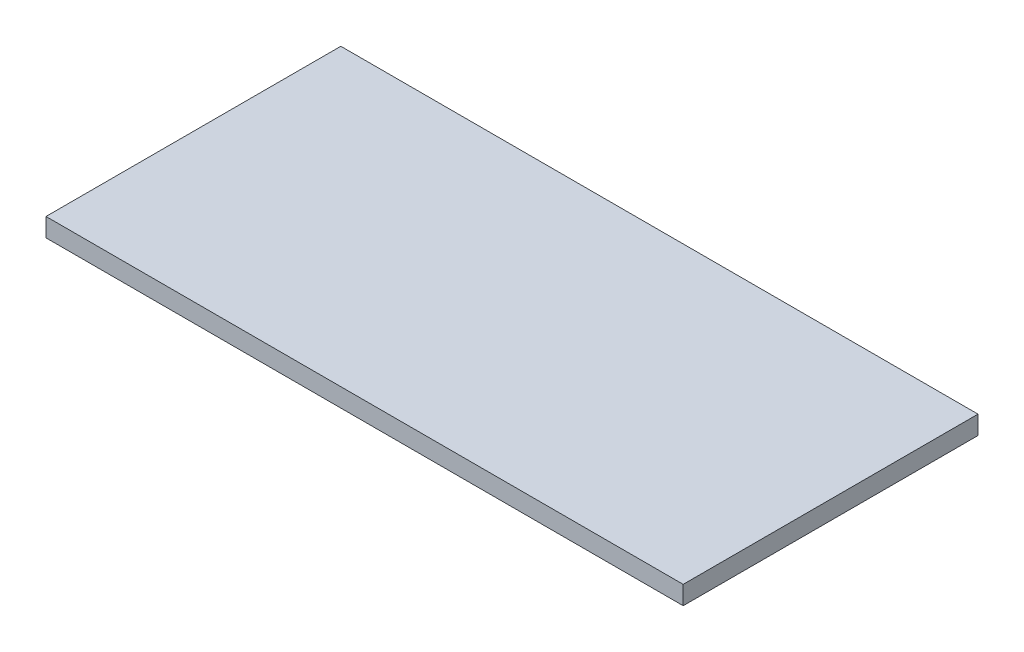
from build123d import *

# Parameters (mm, degrees)
SKETCH_1_W      = 134
SKETCH_1_H      = 3.9
EXTRUDE_1_DEPTH = 62


with BuildPart() as part:
    # 草图1 → 凸台-拉伸1 (new body)
    with BuildSketch(Plane.XY):
        with Locations((67, 1.95)):
            Rectangle(SKETCH_1_W, SKETCH_1_H)
    extrude(amount=EXTRUDE_1_DEPTH)


solid = part.part
